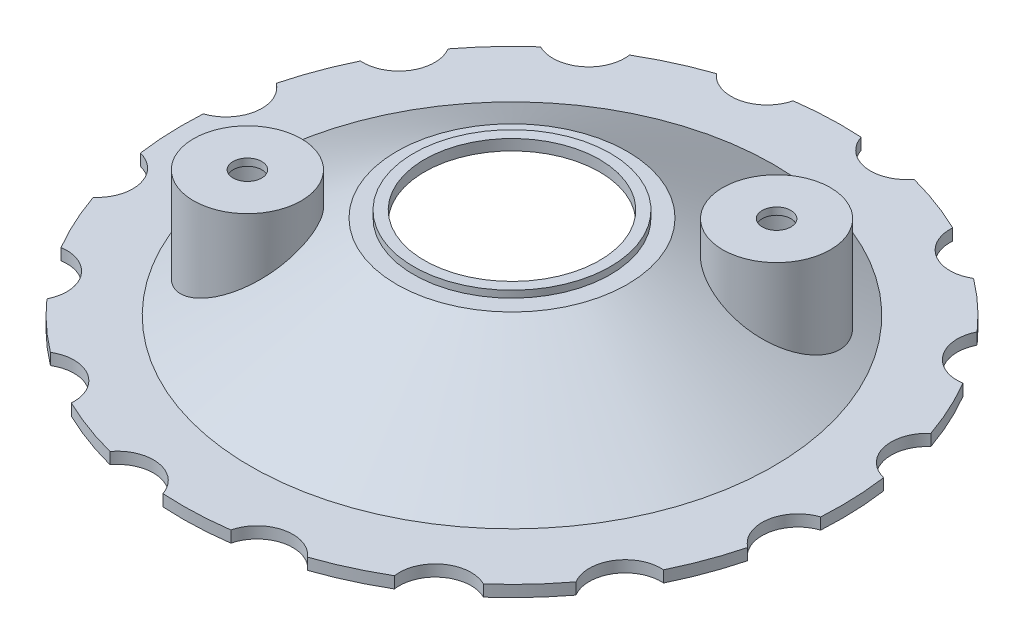
from build123d import *

# Parameters (mm, degrees)
BOSS_EXTRUDE1_DEPTH  = 1
SKETCH4_6_R          = 3.75
SKETCH4_6_R_2        = 2.25
BOSS_EXTRUDE2_DEPTH  = 9.2
SKETCH6_R            = 3.75
SKETCH6_R_2          = 1
BOSS_EXTRUDE10_DEPTH = 0.5
SKETCH4_8_R          = 2.25
CUT_EXTRUDE1_DEPTH   = 8
CUT_EXTRUDE3_DEPTH   = 1.59
SKETCH4_11_R         = 2.5
CUT_EXTRUDE4_DEPTH   = 30


with BuildPart() as part:
    # Sketch3 → Revolve1 (revolve)
    with BuildSketch(Plane.XY, mode=Mode.PRIVATE) as revolve1_sk:
        Polygon((6.1, 8.75), (6.1, 8), (19.956406461, 0), (22.956406461, 0), (22.956406461, 2.39), (18.21680503, 2.39), (8.032346282, 8.27), (6.85, 8.27), (6.85, 8.75), align=None)
    revolve(revolve1_sk.sketch.rotate(Axis((0, 0, 0), (0, 1, 0)), 90), axis=Axis((0, 0, 0), (0, 1, 0)))

    # Sketch4 → Boss-Extrude1 (add)
    with BuildSketch(Plane(origin=(0, 0, 0), x_dir=(1, 0, 0), z_dir=(0, 1, 0))):
        with BuildLine():
            add(Edge.make_bspline(
                [(37.895387387, -37.321572029), (30.563098097, -49.443338403), (7.053757736, -66.606268372), (-36.596901503, -52.447490814), (-49.737650104, -17.65508714), (-51.969553175, 4.189859515), (-49.309208324, 25.910956429), (-32.187838826, 46.978730622), (-4.61708235, 56.277007075), (26.666708419, 51.503030779), (51.443178205, 21.987800167), (49.01371842, -13.034005255), (43.873543884, -26.760869663), (38.465311245, -36.379371908), (37.895387387, -37.321572029)],
                knots=[0, 0, 0, 0, 0.104423524, 0.202068923, 0.320061629, 0.340993137, 0.411383998, 0.528958951, 0.581299976, 0.689189026, 0.813784273, 0.918833729, 0.991883373, 1, 1, 1, 1], degree=3))
        make_face()
        with BuildLine():
            ThreePointArc((2.439836065, -47.754136574), (-0.436166877, -48.958659056), (0.723068185, -46.064105308))
            ThreePointArc((0.723068185, -46.064105308), (1.935360082, -46.549614093), (2.439836065, -47.754136574))
        make_face(mode=Mode.SUBTRACT)
        with BuildLine():
            ThreePointArc((-31.070688274, 26.633047602), (-31.16872293, 26.06401767), (-31.451523068, 25.560599414))
            ThreePointArc((-31.451523068, 25.560599414), (-34.373551524, 27.202077534), (-31.070688274, 26.633047602))
        make_face(mode=Mode.SUBTRACT)
        with BuildLine():
            ThreePointArc((-22.73907703, -3.151344701), (-22.888909513, -1.759096045), (-22.953578803, -0.360302288))
            ThreePointArc((-22.953578803, -0.360302288), (-22.950427117, 0.523920531), (-22.913225839, 1.407366055))
            ThreePointArc((-22.913225839, 1.407366055), (-26.169218782, 4.17396554), (-22.214135262, 5.790405178))
            ThreePointArc((-22.214135262, 5.790405178), (-21.52885089, 7.969013549), (-20.630484704, 10.068748604))
            ThreePointArc((-20.630484704, 10.068748604), (-22.579898155, 13.870767797), (-18.307292773, 13.850618358))
            ThreePointArc((-18.307292773, 13.850618358), (-18.063902311, 14.166581482), (-17.815059338, 14.478268486))
            ThreePointArc((-17.815059338, 14.478268486), (-16.566874203, 15.891358555), (-15.206939289, 17.197255451))
            ThreePointArc((-15.206939289, 17.197255451), (-15.552992722, 21.455871397), (-11.613330915, 19.802200449))
            ThreePointArc((-11.613330915, 19.802200449), (-9.588252936, 20.858139975), (-7.468275218, 21.707636049))
            ThreePointArc((-7.468275218, 21.707636049), (-6.449839638, 25.685752811), (-3.077314839, 23.342955237))
            ThreePointArc((-3.077314839, 23.342955237), (-3.095891321, 23.038755751), (-3.151344701, 22.73907703))
            ThreePointArc((-3.151344701, 22.73907703), (-0.876326041, 22.939674153), (1.407366055, 22.913225839))
            ThreePointArc((1.407366055, 22.913225839), (3.381492859, 26.168427077), (6.280195206, 23.700424558))
            ThreePointArc((6.280195206, 23.700424558), (6.15459249, 22.917968466), (5.790405178, 22.214135262))
            ThreePointArc((5.790405178, 22.214135262), (7.969013549, 21.52885089), (10.068748604, 20.630484704))
            ThreePointArc((10.068748604, 20.630484704), (12.652646811, 22.948082597), (15.062204798, 20.449719084))
            ThreePointArc((15.062204798, 20.449719084), (14.738329093, 19.219075736), (13.850618358, 18.307292773))
            ThreePointArc((13.850618358, 18.307292773), (15.601143065, 16.840455238), (17.197255451, 15.206939289))
            ThreePointArc((17.197255451, 15.206939289), (17.990996228, 16.12883443), (19.125883797, 16.566950029))
            ThreePointArc((19.125883797, 16.566950029), (21.087839169, 15.958510875), (21.931732586, 14.085729257))
            ThreePointArc((21.931732586, 14.085729257), (21.325956656, 12.454191587), (19.802200449, 11.613330915))
            ThreePointArc((19.802200449, 11.613330915), (20.858139975, 9.588252936), (21.707636049, 7.468275218))
            ThreePointArc((21.707636049, 7.468275218), (24.382595086, 7.850891093), (25.842955237, 5.577314839))
            ThreePointArc((25.842955237, 5.577314839), (24.882485113, 3.607581923), (22.73907703, 3.151344701))
            ThreePointArc((22.73907703, 3.151344701), (22.902009654, 1.579414884), (22.956406461, 0))
            ThreePointArc((22.956406461, 0), (22.945608766, -0.704014165), (22.913225839, -1.407366055))
            ThreePointArc((22.913225839, -1.407366055), (25.163640742, -1.753128755), (26.200424558, -3.780195206))
            ThreePointArc((26.200424558, -3.780195206), (24.82609697, -6.012427635), (22.214135262, -5.790405178))
            ThreePointArc((22.214135262, -5.790405178), (21.52885089, -7.969013549), (20.630484704, -10.068748604))
            ThreePointArc((20.630484704, -10.068748604), (22.280281027, -10.859547177), (22.949719084, -12.562204798))
            ThreePointArc((22.949719084, -12.562204798), (21.118275074, -14.9711533), (18.307292773, -13.850618358))
            ThreePointArc((18.307292773, -13.850618358), (16.840455238, -15.601143065), (15.206939289, -17.197255451))
            ThreePointArc((15.206939289, -17.197255451), (16.213289489, -18.118915972), (16.585729257, -19.431732586))
            ThreePointArc((16.585729257, -19.431732586), (14.271476592, -21.924822622), (11.613330915, -19.802200449))
            ThreePointArc((11.613330915, -19.802200449), (9.588252936, -20.858139975), (7.468275218, -21.707636049))
            ThreePointArc((7.468275218, -21.707636049), (7.920112413, -22.470430437), (8.077314839, -23.342955237))
            ThreePointArc((8.077314839, -23.342955237), (5.273115352, -25.824378754), (3.151344701, -22.73907703))
            ThreePointArc((3.151344701, -22.73907703), (1.759096045, -22.888909513), (0.360302288, -22.953578803))
            ThreePointArc((0.360302288, -22.953578803), (-0.523920531, -22.950427117), (-1.407366055, -22.913225839))
            ThreePointArc((-1.407366055, -22.913225839), (-1.312192686, -23.30172221), (-1.280195206, -23.700424558))
            ThreePointArc((-1.280195206, -23.700424558), (-4.562651297, -26.074821842), (-5.790405178, -22.214135262))
            ThreePointArc((-5.790405178, -22.214135262), (-7.969013549, -21.52885089), (-10.068748604, -20.630484704))
            ThreePointArc((-10.068748604, -20.630484704), (-13.870767797, -22.579898155), (-13.850618358, -18.307292773))
            ThreePointArc((-13.850618358, -18.307292773), (-15.601143065, -16.840455238), (-17.197255451, -15.206939289))
            ThreePointArc((-17.197255451, -15.206939289), (-21.455871397, -15.552992722), (-19.802200449, -11.613330915))
            ThreePointArc((-19.802200449, -11.613330915), (-20.858139975, -9.588252936), (-21.707636049, -7.468275218))
            ThreePointArc((-21.707636049, -7.468275218), (-25.774513074, -6.158285134), (-22.73907703, -3.151344701))
        make_face(mode=Mode.SUBTRACT)
        with BuildLine():
            ThreePointArc((33.428094542, 27.478844668), (32.31888351, 25.88142274), (30.434591067, 26.362617002))
            ThreePointArc((30.434591067, 26.362617002), (31.127579365, 29.076266596), (33.428094542, 27.478844668))
        make_face(mode=Mode.SUBTRACT)
    extrude(amount=BOSS_EXTRUDE1_DEPTH)

    # Sketch4_6 → Boss-Extrude2 (add)
    with BuildSketch(Plane(origin=(0, 0, 0), x_dir=(1, 0, 0), z_dir=(0, 1, 0))):
        with Locations(Location((10.6926445, 7.739984082, 0), (0, 0, 128.802373027))):
            Circle(SKETCH4_6_R)
        with Locations(Location((10.6926445, 7.739984082, 0), (0, 0, 123.851019064))):
            Circle(SKETCH4_6_R_2, mode=Mode.SUBTRACT)
        with Locations(Location((-10.6926445, -7.739984082, 0), (0, 0, 136.734917526))):
            Circle(SKETCH4_6_R)
        with Locations(Location((-10.6926445, -7.739984082, 0), (0, 0, 132.932943945))):
            Circle(SKETCH4_6_R_2, mode=Mode.SUBTRACT)
    extrude(amount=BOSS_EXTRUDE2_DEPTH)

    # Sketch3_4 → Cut-Revolve1 (revolve, cut)
    with BuildSketch(Plane.XY):
        Polygon((6.1, 0), (0, 0), (0, 8), (6.1, 8), (19.956406461, 0), align=None)
    revolve(axis=Axis((0, 0, 0), (0, 1, 0)), mode=Mode.SUBTRACT)

    # Sketch6 → Boss-Extrude10 (add)
    with BuildSketch(Plane(origin=(0, 9.2, 0), x_dir=(1, 0, 0), z_dir=(0, 1, 0))):
        with Locations(Location((-10.6926445, -7.739984082, 0), (0, 0, 140.066747093))):
            Circle(SKETCH6_R)
        with Locations(Location((-10.6926445, -7.739984082, 0), (0, 0, 270))):
            Circle(SKETCH6_R_2, mode=Mode.SUBTRACT)
        with Locations(Location((10.6926445, 7.739984082, 0), (0, 0, 125.244131544))):
            Circle(SKETCH6_R)
        with Locations(Location((10.6926445, 7.739984082, 0), (0, 0, 270))):
            Circle(SKETCH6_R_2, mode=Mode.SUBTRACT)
    extrude(amount=BOSS_EXTRUDE10_DEPTH)

    # Sketch4_8 → Cut-Extrude1 (cut)
    with BuildSketch(Plane(origin=(0, 0, 0), x_dir=(1, 0, 0), z_dir=(0, 1, 0))):
        with Locations(Location((-10.6926445, -7.739984082, 0), (0, 0, 132.932943945))):
            Circle(SKETCH4_8_R)
        with Locations(Location((10.6926445, 7.739984082, 0), (0, 0, 123.851019064))):
            Circle(SKETCH4_8_R)
    extrude(amount=CUT_EXTRUDE1_DEPTH, mode=Mode.SUBTRACT)

    # Sketch4_10 → Cut-Extrude3 (cut)
    with BuildSketch(Plane(origin=(0, 0, 0), x_dir=(1, 0, 0), z_dir=(0, 1, 0))):
        with BuildLine():
            add(Edge.make_bspline(
                [(37.895387387, -37.321572029), (30.563098097, -49.443338403), (7.053757736, -66.606268372), (-36.596901503, -52.447490814), (-49.737650104, -17.65508714), (-51.969553175, 4.189859515), (-49.309208324, 25.910956429), (-32.187838826, 46.978730622), (-4.61708235, 56.277007075), (26.666708419, 51.503030779), (51.443178205, 21.987800167), (49.01371842, -13.034005255), (43.873543884, -26.760869663), (38.465311245, -36.379371908), (37.895387387, -37.321572029)],
                knots=[0, 0, 0, 0, 0.104423524, 0.202068923, 0.320061629, 0.340993137, 0.411383998, 0.528958951, 0.581299976, 0.689189026, 0.813784273, 0.918833729, 0.991883373, 1, 1, 1, 1], degree=3))
        make_face()
    extrude(amount=CUT_EXTRUDE3_DEPTH, mode=Mode.SUBTRACT)

    # Sketch4_11 → Cut-Extrude4 (cut)
    with BuildSketch(Plane(origin=(0, 0, 0), x_dir=(1, 0, 0), z_dir=(0, 1, 0))):
        with Locations((-19.431732586, -14.085729257)):
            Circle(SKETCH4_11_R)
        with Locations((-23.342955237, -5.577314839)):
            Circle(SKETCH4_11_R)
        with Locations((-23.700424558, 3.780195206)):
            Circle(SKETCH4_11_R)
        with Locations((-20.449719084, 12.562204798)):
            Circle(SKETCH4_11_R)
        with Locations((-14.085729257, 19.431732586)):
            Circle(SKETCH4_11_R)
        with Locations((-5.577314839, 23.342955237)):
            Circle(SKETCH4_11_R)
        with Locations((3.780195206, 23.700424558)):
            Circle(SKETCH4_11_R)
        with Locations((12.562204798, 20.449719084)):
            Circle(SKETCH4_11_R)
        with Locations((19.431732586, 14.085729257)):
            Circle(SKETCH4_11_R)
        with Locations((23.342955237, 5.577314839)):
            Circle(SKETCH4_11_R)
        with Locations((23.700424558, -3.780195206)):
            Circle(SKETCH4_11_R)
        with Locations((20.449719084, -12.562204798)):
            Circle(SKETCH4_11_R)
        with Locations((14.085729257, -19.431732586)):
            Circle(SKETCH4_11_R)
        with Locations((5.577314839, -23.342955237)):
            Circle(SKETCH4_11_R)
        with Locations((-3.780195206, -23.700424558)):
            Circle(SKETCH4_11_R)
        with Locations((-12.562204798, -20.449719084)):
            Circle(SKETCH4_11_R)
    extrude(amount=CUT_EXTRUDE4_DEPTH, mode=Mode.SUBTRACT)


solid = part.part
